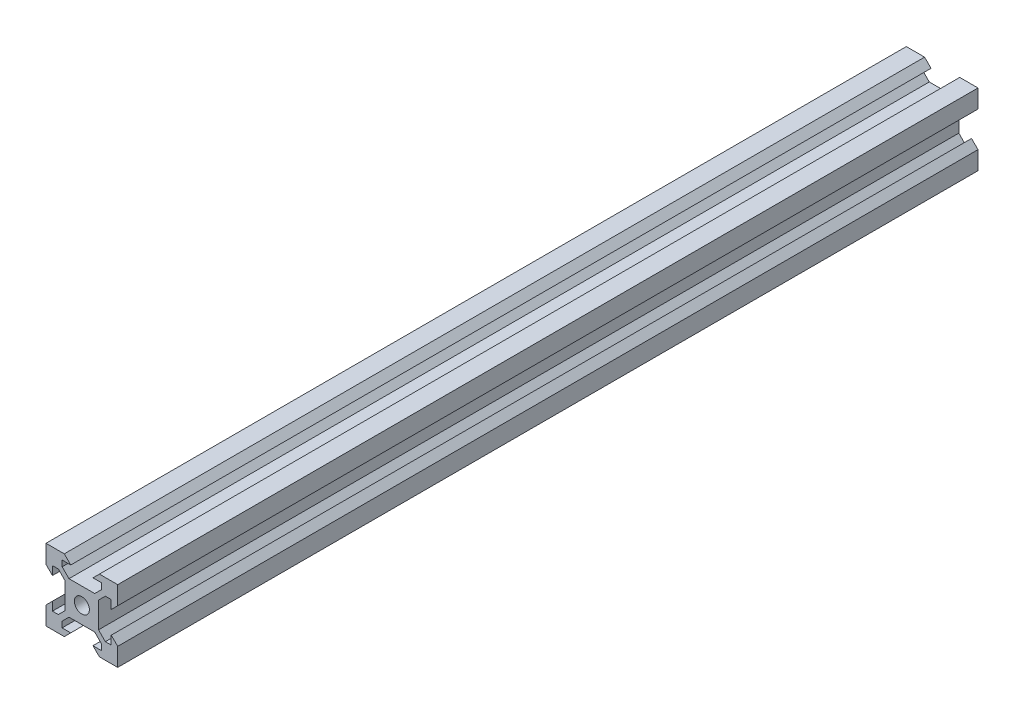
from build123d import *

# Parameters (mm, degrees)
SKETCH1_R           = 2.1
BOSS_EXTRUDE1_DEPTH = 120


with BuildPart() as part:
    # Sketch1 → Boss-Extrude1 (new body, symmetric)
    with BuildSketch(Plane.XY):
        Polygon((5.499339828, 6.56), (3.59, 4.650660172), (-3.59, 4.650660172), (-5.499339828, 6.56), (-5.499339828, 8.2), (-3.1, 8.2), (-4.9, 10), (-10, 10), (-10, 4.9), (-8.2, 3.1), (-8.2, 5.499339828), (-6.56, 5.499339828), (-4.650660172, 3.59), (-4.650660172, -3.59), (-6.56, -5.499339828), (-8.2, -5.499339828), (-8.2, -3.1), (-10, -4.9), (-10, -10), (-4.9, -10), (-3.1, -8.2), (-5.499339828, -8.2), (-5.499339828, -6.56), (-3.59, -4.650660172), (3.59, -4.650660172), (5.499339828, -6.56), (5.499339828, -8.2), (3.1, -8.2), (4.9, -10), (10, -10), (10, -4.9), (8.2, -3.1), (8.2, -5.499339828), (6.56, -5.499339828), (4.650660172, -3.59), (4.650660172, 3.59), (6.56, 5.499339828), (8.2, 5.499339828), (8.2, 3.1), (10, 4.9), (10, 10), (4.9, 10), (3.1, 8.2), (5.499339828, 8.2), align=None)
        Circle(SKETCH1_R, mode=Mode.SUBTRACT)
    extrude(amount=BOSS_EXTRUDE1_DEPTH, both=True)


solid = part.part
